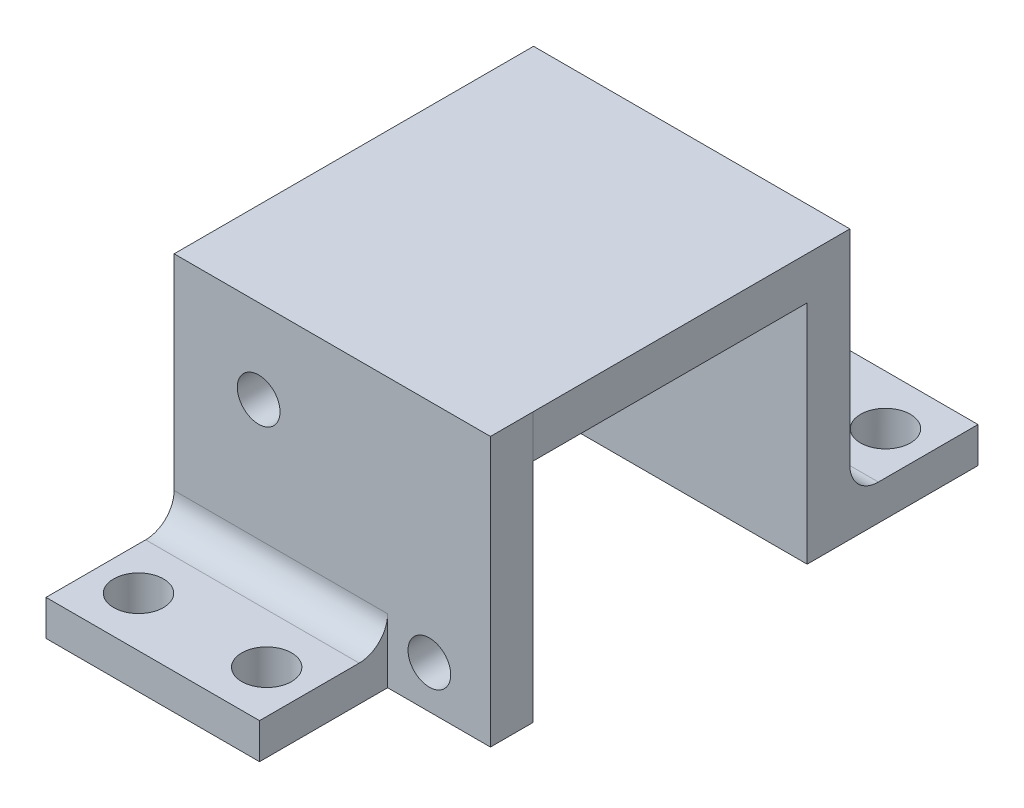
from build123d import *

# Parameters (mm, degrees)
SKETCH1_W             = 22.22
SKETCH1_H             = 15.9
SKETCH1_R             = 1.5
BOSS_EXTRUDE1_DEPTH   = 3
SKETCH3_W             = 9
SKETCH3_H             = 2.5
BOSS_EXTRUDE2_DEPTH   = 15
FILLET2_R             = 2
CUT_EXTRUDE1_REACH    = 4.5
SKETCH5_R             = 1.75
LPATTERN2_COUNT       = 2
LPATTERN2_PITCH       = 6.95
BODY_MOVE_COPY3_ANGLE = 180
SKETCH11_W            = 22.249975
SKETCH11_H            = 3
BOSS_EXTRUDE3_DEPTH   = 22.22
SKETCH12_W            = 3
SKETCH12_H            = 3
BOSS_EXTRUDE4_DEPTH   = 22.22


with BuildPart() as part:
    # Sketch1 → Boss-Extrude1 (new body)
    with BuildSketch(Plane.XY):
        Rectangle(SKETCH1_W, SKETCH1_H)
        with Locations((-5.17, 5.05)):
            Circle(SKETCH1_R, mode=Mode.SUBTRACT)
        with Locations((6.82, -4.95)):
            Circle(SKETCH1_R, mode=Mode.SUBTRACT)
    extrude(amount=BOSS_EXTRUDE1_DEPTH)

    # Sketch3 → Boss-Extrude2 (add)
    with BuildSketch(Plane.ZY.offset(11.11)):
        with Locations((7.5, -6.7)):
            Rectangle(SKETCH3_W, SKETCH3_H)
    extrude(amount=-BOSS_EXTRUDE2_DEPTH)

    # Fillet2
    fillet2_edges = [part.edges().sort_by_distance(p)[0] for p in [
        (-3.61, -5.45, 3),
    ]]
    fillet(fillet2_edges, radius=FILLET2_R)

    # Sketch5 → Cut-Extrude1 (cut, up to next)
    with BuildSketch(Plane(origin=(0, -5.45, 0), x_dir=(1, 0, 0), z_dir=(0, 1, 0)), mode=Mode.PRIVATE) as cut_extrude1_sk1:
        with Locations((-8.11, -8.5)):
            Circle(SKETCH5_R)
    cut_extrude1_tool1 = extrude(cut_extrude1_sk1.sketch, amount=-CUT_EXTRUDE1_REACH, mode=Mode.PRIVATE) & part.part
    add(cut_extrude1_tool1.solids().sort_by_distance((-8.11, -5.45, 8.5))[0], mode=Mode.SUBTRACT)
    # Sketch5 → Cut-Extrude1 (cut, up to next)
    with BuildSketch(Plane(origin=(0, -5.45, 0), x_dir=(1, 0, 0), z_dir=(0, 1, 0)), mode=Mode.PRIVATE) as cut_extrude1_sk2:
        with Locations((0.89, -8.5)):
            Circle(SKETCH5_R)
    cut_extrude1_tool2 = extrude(cut_extrude1_sk2.sketch, amount=-CUT_EXTRUDE1_REACH, mode=Mode.PRIVATE) & part.part
    add(cut_extrude1_tool2.solids().sort_by_distance((0.89, -5.45, 8.5))[0], mode=Mode.SUBTRACT)


with BuildPart() as lpattern2_1:
    # LPattern2: pattern copy
    add(part.part.moved(Location(Vector(0, 0, -1) * (1 * LPATTERN2_PITCH))))


with BuildPart() as lpattern2_1_1:
    # Body-Move/Copy3: moved
    add(lpattern2_1.part.rotate(Axis((1.25e-05, 0, -13.0999875), (0, 1, 0)), BODY_MOVE_COPY3_ANGLE))

    # Sketch11 → Boss-Extrude3 (add)
    with BuildSketch(Plane.ZY.offset(11.109975)):
        with Locations((-11.1249875, 9.45)):
            Rectangle(SKETCH11_W, SKETCH11_H)
    extrude(amount=-BOSS_EXTRUDE3_DEPTH)


with BuildPart() as part_1:
    add(part.part)

    add(lpattern2_1_1.part)  # Boss-Extrude4 merges LPattern2_1
    # Sketch12 → Boss-Extrude4 (add)
    with BuildSketch(Plane.ZY.offset(11.109975)):
        with Locations((1.5, 9.45)):
            Rectangle(SKETCH12_W, SKETCH12_H)
    extrude(amount=-BOSS_EXTRUDE4_DEPTH)


solid = part_1.part
